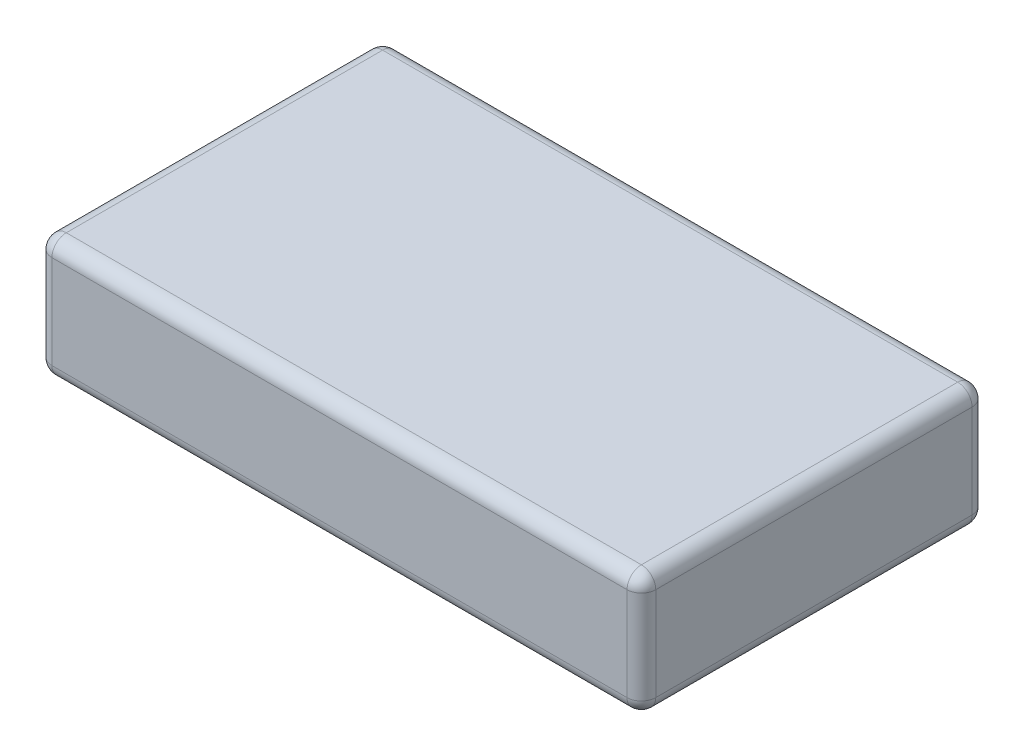
from build123d import *

# Parameters (mm, degrees)
SKETCH1_W           = 42
SKETCH1_H           = 24
BOSS_EXTRUDE1_DEPTH = 8.5
FILLET1_R           = 1


with BuildPart() as part:
    # Sketch1 → Boss-Extrude1 (new body)
    with BuildSketch(Plane(origin=(0, 0, 0), x_dir=(1, 0, 0), z_dir=(0, 1, 0))):
        Rectangle(SKETCH1_W, SKETCH1_H)
    extrude(amount=BOSS_EXTRUDE1_DEPTH)

    # Fillet1
    fillet1_edges = [part.edges().sort_by_distance(p)[0] for p in [
        (21, 8.5, 0),
        (0, 8.5, -12),
        (-21, 8.5, 0),
        (0, 0, -12),
        (21, 0, 0),
        (0, 0, 12),
        (-21, 0, 0),
        (0, 8.5, 12),
        (-21, 4.25, -12),
        (21, 4.25, -12),
        (21, 4.25, 12),
        (-21, 4.25, 12),
    ]]
    fillet(fillet1_edges, radius=FILLET1_R)


solid = part.part
